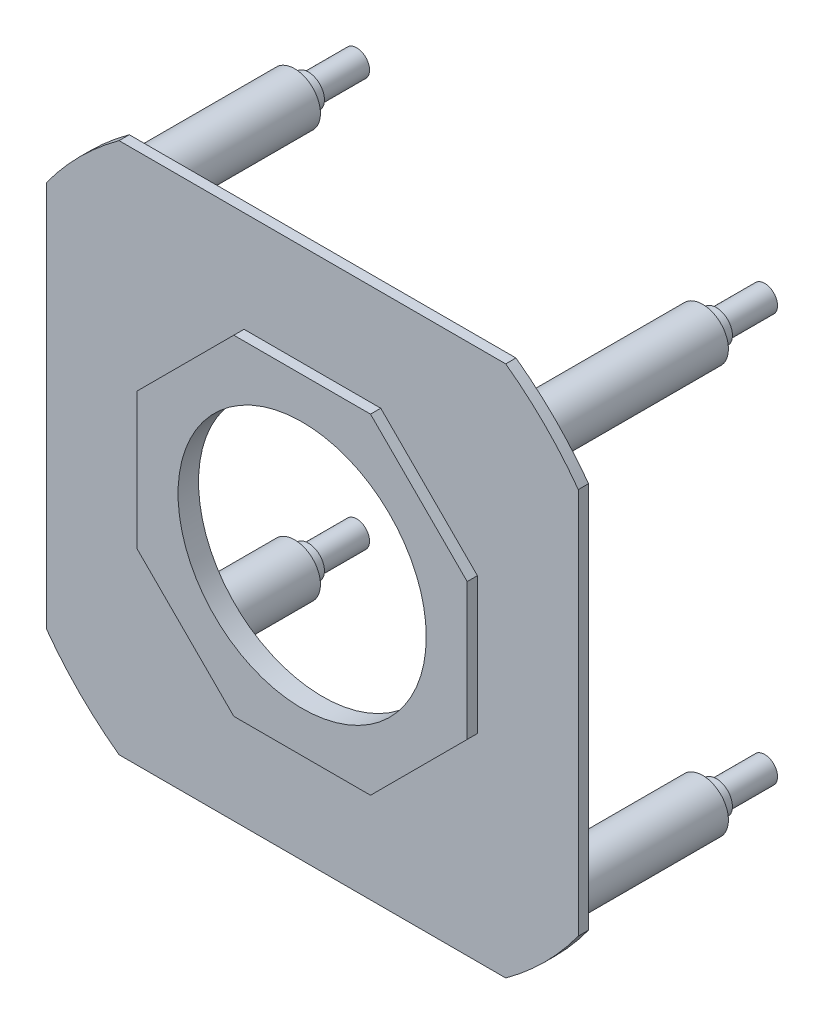
from build123d import *

# Parameters (mm, degrees)
SKETCH1_W           = 203.947710216
SKETCH1_H           = 203.947710216
SKETCH1_R           = 38.5
BOSS_EXTRUDE1_DEPTH = 3.175
SKETCH1_3_R         = 38.5
BOSS_EXTRUDE2_DEPTH = 6.35
SKETCH2_R           = 8
BOSS_EXTRUDE3_DEPTH = 54.60355498
SKETCH3_R           = 5
BOSS_EXTRUDE4_DEPTH = 4.25
SKETCH4_R           = 4
BOSS_EXTRUDE5_DEPTH = 15
SKETCH6_W           = 203.947710216
SKETCH6_H           = 203.947710216
CUT_EXTRUDE1_DEPTH  = 15


with BuildPart() as part:
    # Sketch1 → Boss-Extrude1 (new body)
    with BuildSketch(Plane.XY):
        Rectangle(SKETCH1_W, SKETCH1_H)
        Polygon((51.2, 21.207734394), (21.207734394, 51.2), (-21.207734394, 51.2), (-51.2, 21.207734394), (-51.2, -21.207734394), (-21.207734394, -51.2), (21.207734394, -51.2), (51.2, -21.207734394), align=None, mode=Mode.SUBTRACT)
        Polygon((51.2, -21.207734394), (51.2, 21.207734394), (21.207734394, 51.2), (-21.207734394, 51.2), (-51.2, 21.207734394), (-51.2, -21.207734394), (-21.207734394, -51.2), (21.207734394, -51.2), align=None)
        Circle(SKETCH1_R, mode=Mode.SUBTRACT)
    extrude(amount=BOSS_EXTRUDE1_DEPTH)

    # Sketch1_3 → Boss-Extrude2 (add)
    with BuildSketch(Plane.XY):
        Polygon((51.2, -21.207734394), (51.2, 21.207734394), (21.207734394, 51.2), (-21.207734394, 51.2), (-51.2, 21.207734394), (-51.2, -21.207734394), (-21.207734394, -51.2), (21.207734394, -51.2), align=None)
        Circle(SKETCH1_3_R, mode=Mode.SUBTRACT)
    extrude(amount=BOSS_EXTRUDE2_DEPTH)

    # Sketch2 → Boss-Extrude3 (add)
    with BuildSketch(Plane(origin=(0, 0, 0), x_dir=(-1, 0, 0), z_dir=(0, 0, -1))):
        with Locations(Location((-63.286056916, 63.286056916, 0), (0, 0, 180))):
            Circle(SKETCH2_R)
    boss_extrude3 = extrude(amount=BOSS_EXTRUDE3_DEPTH)

    # Sketch3 → Boss-Extrude4 (add)
    with BuildSketch(Plane(origin=(0, 0, -54.60355498), x_dir=(-1, 0, 0), z_dir=(0, 0, -1))):
        with Locations((-63.286056916, 63.286056916)):
            Circle(SKETCH3_R)
    boss_extrude4 = extrude(amount=BOSS_EXTRUDE4_DEPTH)

    # Sketch4 → Boss-Extrude5 (add)
    with BuildSketch(Plane(origin=(0, 0, -58.85355498), x_dir=(-1, 0, 0), z_dir=(0, 0, -1))):
        with Locations((-63.286056916, 63.286056916)):
            Circle(SKETCH4_R)
    boss_extrude5 = extrude(amount=BOSS_EXTRUDE5_DEPTH)

    # Sketch-Pattern1: Boss-Extrude3, Boss-Extrude4, Boss-Extrude5 at 3 more places
    with Locations((-126.572114, 0, 0), (-126.572114, -126.572114, 0), (0, -126.572114, 0)):
        add(boss_extrude3)
        add(boss_extrude4)
        add(boss_extrude5)

    # Sketch6 → Cut-Extrude1 (cut)
    with BuildSketch(Plane(origin=(0, 0, 0), x_dir=(-1, 0, 0), z_dir=(0, 0, -1))):
        Rectangle(SKETCH6_W, SKETCH6_H)
        with BuildLine():
            ThreePointArc((-59.981247069, 82.5), (-72.124891681, 72.124891681), (-82.5, 59.981247069))
            Line((-82.5, 59.981247069), (-82.5, -59.981247069))
            ThreePointArc((-82.5, -59.981247069), (-72.124891681, -72.124891681), (-59.981247069, -82.5))
            Line((-59.981247069, -82.5), (59.981247069, -82.5))
            ThreePointArc((59.981247069, -82.5), (72.124891681, -72.124891681), (82.5, -59.981247069))
            Line((82.5, -59.981247069), (82.5, 59.981247069))
            ThreePointArc((82.5, 59.981247069), (72.124891681, 72.124891681), (59.981247069, 82.5))
            Line((59.981247069, 82.5), (-59.981247069, 82.5))
        make_face(mode=Mode.SUBTRACT)
    extrude(amount=-CUT_EXTRUDE1_DEPTH, mode=Mode.SUBTRACT)


solid = part.part
